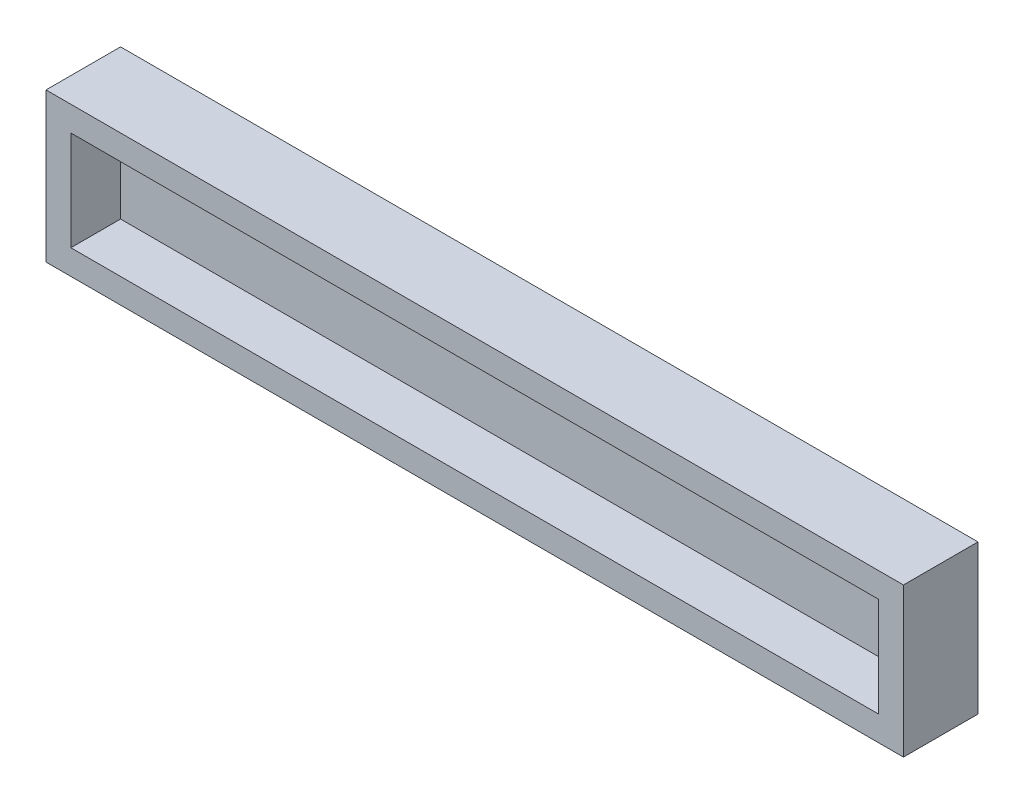
from build123d import *

# Parameters (mm, degrees)
SKETCH1_W           = 97.5
SKETCH1_H           = 12
BOSS_EXTRUDE1_DEPTH = 3
SKETCH2_W           = 103.5
SKETCH2_H           = 18
SKETCH2_W_2         = 97.5
SKETCH2_H_2         = 12
BOSS_EXTRUDE2_DEPTH = 9


with BuildPart() as part:
    # Sketch1 → Boss-Extrude1 (new body)
    with BuildSketch(Plane.XY):
        with Locations((48.75, 6)):
            Rectangle(SKETCH1_W, SKETCH1_H)
    extrude(amount=BOSS_EXTRUDE1_DEPTH)

    # Sketch2 → Boss-Extrude2 (add)
    with BuildSketch(Plane(origin=(0, 0, 0), x_dir=(-1, 0, 0), z_dir=(0, 0, -1))):
        with Locations((-48.75, 6)):
            Rectangle(SKETCH2_W, SKETCH2_H)
        with Locations((-48.75, 6)):
            Rectangle(SKETCH2_W_2, SKETCH2_H_2, mode=Mode.SUBTRACT)
    extrude(amount=-BOSS_EXTRUDE2_DEPTH)


solid = part.part
